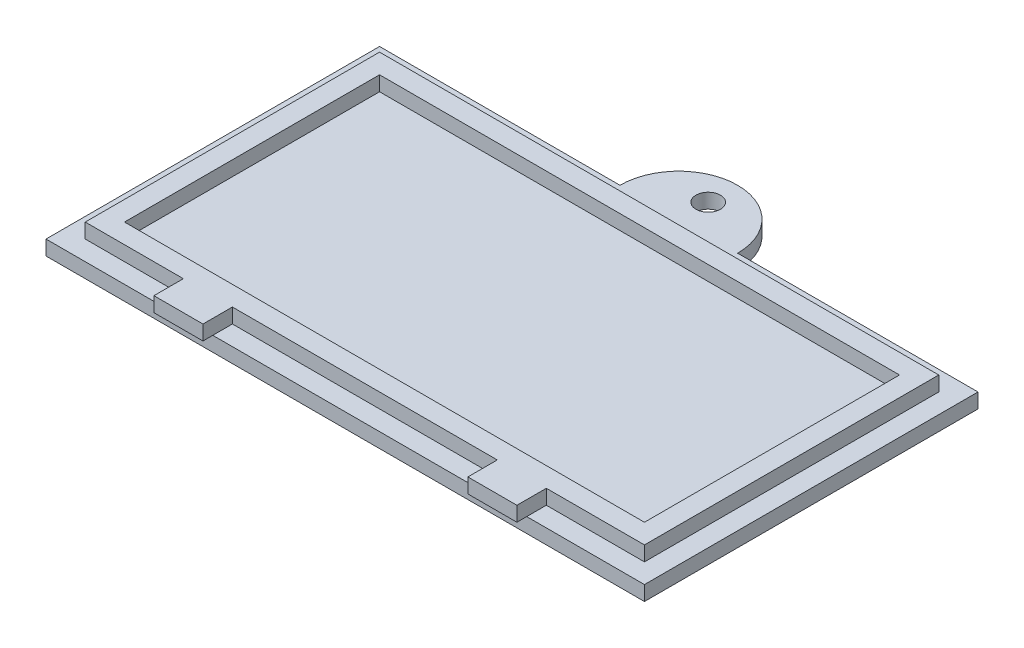
from build123d import *

# Parameters (mm, degrees)
SKETCH1_W             = 61
SKETCH1_H             = 34
BOSS_EXTRUDE1_DEPTH   = 1.5
SKETCH2_W             = 57
SKETCH2_H             = 30
BOSS_EXTRUDE2_DEPTH   = 1.5
SKETCH3_W             = 53
SKETCH3_H             = 26
CUT_EXTRUDE1_DEPTH    = 1.5
SKETCH4_R             = 6
BOSS_EXTRUDE3_DEPTH   = 1.5
M3_TAPPED_HOLE2_D     = 2.5
M3_TAPPED_HOLE2_DEPTH = 7.5
M3_TAPPED_HOLE2_TIP   = 0.751075774
SKETCH9_W             = 5
SKETCH9_H             = 1.5
BOSS_EXTRUDE4_DEPTH   = 3


with BuildPart() as part:
    # Sketch1 → Boss-Extrude1 (new body)
    with BuildSketch(Plane(origin=(0, 0, 0), x_dir=(1, 0, 0), z_dir=(0, 1, 0))):
        with Locations((30.5, 17)):
            Rectangle(SKETCH1_W, SKETCH1_H)
    extrude(amount=BOSS_EXTRUDE1_DEPTH)

    # Sketch2 → Boss-Extrude2 (add)
    with BuildSketch(Plane(origin=(0, 1.5, 0), x_dir=(1, 0, 0), z_dir=(0, 1, 0))):
        with Locations((30.5, 17)):
            Rectangle(SKETCH2_W, SKETCH2_H)
    extrude(amount=BOSS_EXTRUDE2_DEPTH)

    # Sketch3 → Cut-Extrude1 (cut)
    with BuildSketch(Plane(origin=(0, 3, 0), x_dir=(1, 0, 0), z_dir=(0, 1, 0))):
        with Locations((30.5, 17)):
            Rectangle(SKETCH3_W, SKETCH3_H)
    extrude(amount=-CUT_EXTRUDE1_DEPTH, mode=Mode.SUBTRACT)

    # Sketch4 → Boss-Extrude3 (add)
    with BuildSketch(Plane(origin=(0, 0, 0), x_dir=(-1, 0, 0), z_dir=(0, -1, 0))):
        with Locations((-30.5, 34)):
            Circle(SKETCH4_R)
    extrude(amount=-BOSS_EXTRUDE3_DEPTH)

    # M3 Tapped Hole2
    with Locations(Plane(origin=(30.5, 0, -37), x_dir=(0, 0, -1), z_dir=(0, -1, 0))):
        with Locations((0, 0)):
            Hole(M3_TAPPED_HOLE2_D / 2, depth=M3_TAPPED_HOLE2_DEPTH)
            with Locations((0, 0, -(M3_TAPPED_HOLE2_DEPTH + M3_TAPPED_HOLE2_TIP / 2))):  # 118° drill point
                Cone(0, M3_TAPPED_HOLE2_D / 2, M3_TAPPED_HOLE2_TIP, mode=Mode.SUBTRACT)

    # Sketch9 → Boss-Extrude4 (add)
    with BuildSketch(Plane.XY.offset(-2)):
        with Locations((14.5, 2.25)):
            Rectangle(SKETCH9_W, SKETCH9_H)
        with Locations((46.5, 2.25)):
            Rectangle(SKETCH9_W, SKETCH9_H)
    extrude(amount=BOSS_EXTRUDE4_DEPTH)


solid = part.part
